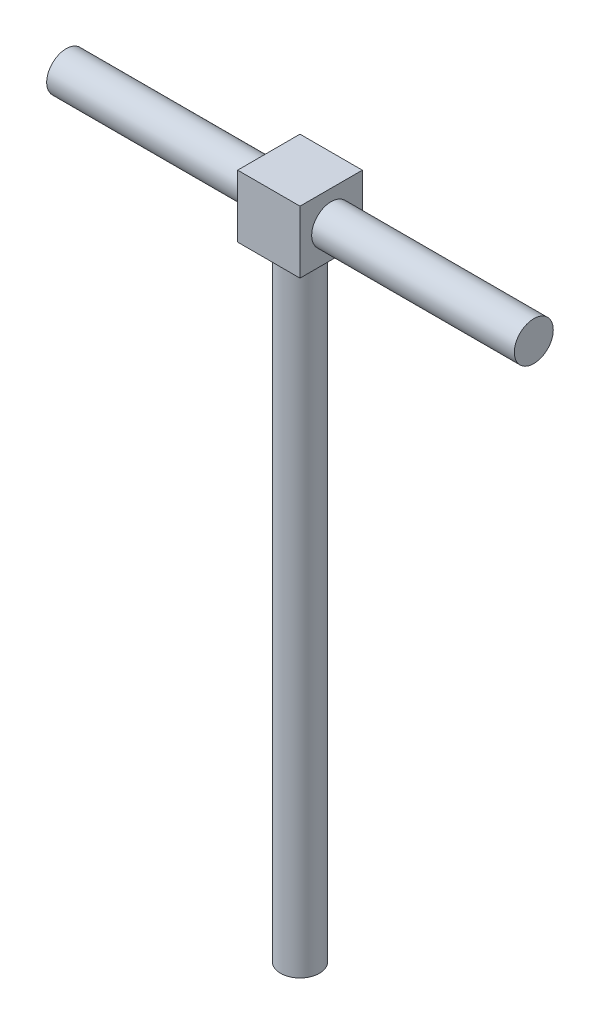
from build123d import *

# Parameters (mm, degrees)
SKETCH1_R           = 2.5
BOSS_EXTRUDE1_DEPTH = 80
SKETCH2_W           = 8
SKETCH2_H           = 8
BOSS_EXTRUDE2_DEPTH = 8
SKETCH3_R           = 2.5
BOSS_EXTRUDE3_DEPTH = 30


with BuildPart() as part:
    # Sketch1 → Boss-Extrude1 (new body)
    with BuildSketch(Plane(origin=(0, 0, 0), x_dir=(1, 0, 0), z_dir=(0, 1, 0))):
        Circle(SKETCH1_R)
    extrude(amount=BOSS_EXTRUDE1_DEPTH)

    # Sketch2 → Boss-Extrude2 (add)
    with BuildSketch(Plane(origin=(0, 80, 0), x_dir=(1, 0, 0), z_dir=(0, 1, 0))):
        Rectangle(SKETCH2_W, SKETCH2_H)
    extrude(amount=BOSS_EXTRUDE2_DEPTH)

    # Sketch3 → Boss-Extrude3 (add, symmetric)
    with BuildSketch(Plane(origin=(0, 0, 0), x_dir=(0, 0, -1), z_dir=(1, 0, 0))):
        with Locations((0, 84)):
            Circle(SKETCH3_R)
    extrude(amount=BOSS_EXTRUDE3_DEPTH, both=True)


solid = part.part
